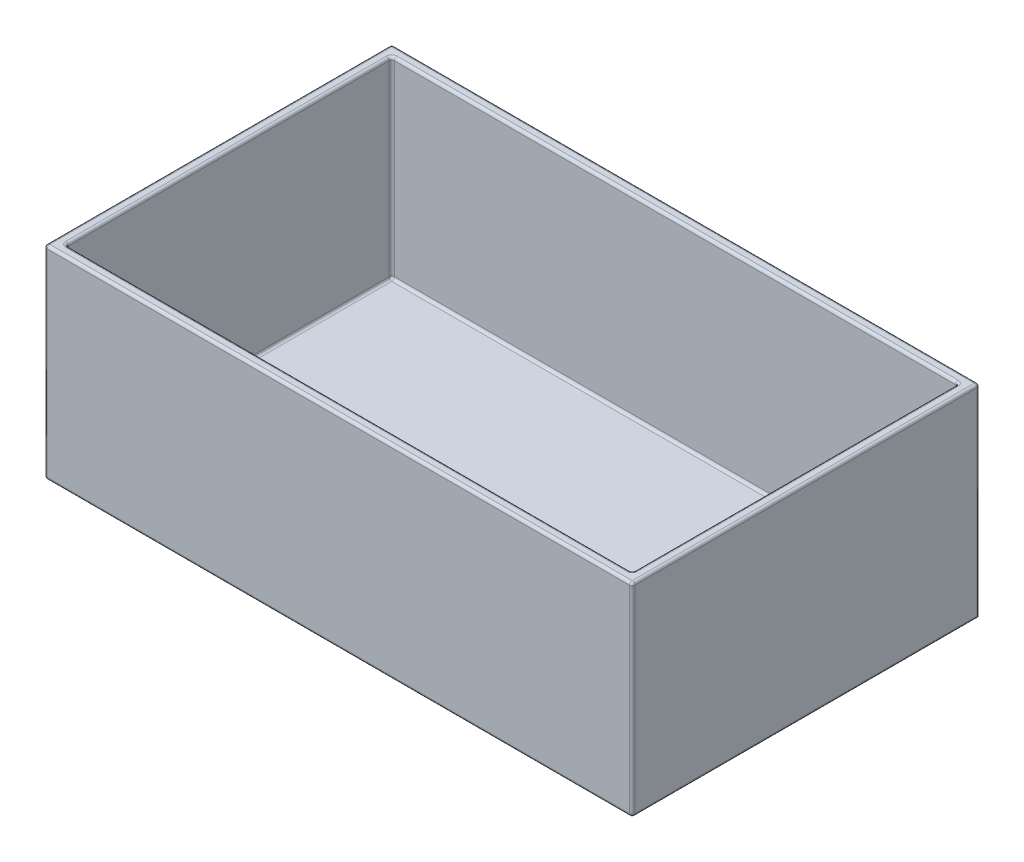
from build123d import *

# Parameters (mm, degrees)
SKETCH1_W           = 110
SKETCH1_H           = 65
BOSS_EXTRUDE1_DEPTH = 38
SKETCH2_W           = 106
SKETCH2_H           = 61
CUT_EXTRUDE1_DEPTH  = 36
SKETCH3_W           = 2
SKETCH3_H           = 61
BOSS_EXTRUDE2_DEPTH = 5
FILLET4_R           = 0.5


with BuildPart() as part:
    # Sketch1 → Boss-Extrude1 (new body)
    with BuildSketch(Plane(origin=(0, 0, 0), x_dir=(1, 0, 0), z_dir=(0, 1, 0))):
        with Locations((11.911764706, 4.558823529)):
            Rectangle(SKETCH1_W, SKETCH1_H)
    extrude(amount=BOSS_EXTRUDE1_DEPTH)

    # Sketch2 → Cut-Extrude1 (cut)
    with BuildSketch(Plane(origin=(0, 38, 0), x_dir=(1, 0, 0), z_dir=(0, 1, 0))):
        with Locations((11.911764706, 4.558823529)):
            Rectangle(SKETCH2_W, SKETCH2_H)
    extrude(amount=-CUT_EXTRUDE1_DEPTH, mode=Mode.SUBTRACT)

    # Sketch3 → Boss-Extrude2 (add)
    with BuildSketch(Plane(origin=(0, 2, 0), x_dir=(1, 0, 0), z_dir=(0, 1, 0))):
        with Locations((37.911764706, 4.558823529)):
            Rectangle(SKETCH3_W, SKETCH3_H)
    extrude(amount=BOSS_EXTRUDE2_DEPTH)

    # Fillet4
    fillet4_edges = [part.edges().sort_by_distance(p)[0] for p in [
        (66.911764706, 38, -4.558823529),
        (11.911764706, 38, -37.058823529),
        (-41.088235294, 2, -4.558823529),
        (-41.088235294, 20, 25.941176471),
        (51.911764706, 2, -35.058823529),
        (-41.088235294, 20, -35.058823529),
        (64.911764706, 2, -4.558823529),
        (64.911764706, 20, -35.058823529),
        (-2.088235294, 2, 25.941176471),
        (64.911764706, 20, 25.941176471),
        (-41.088235294, 38, -4.558823529),
        (11.911764706, 38, 25.941176471),
        (64.911764706, 38, -4.558823529),
        (11.911764706, 38, -35.058823529),
        (51.911764706, 2, 25.941176471),
        (-2.088235294, 2, -35.058823529),
        (37.911764706, 7, -35.058823529),
        (38.911764706, 4.5, -35.058823529),
        (36.911764706, 2, -4.558823529),
        (36.911764706, 4.5, -35.058823529),
        (36.911764706, 4.5, 25.941176471),
        (38.911764706, 7, -4.558823529),
        (38.911764706, 4.5, 25.941176471),
        (36.911764706, 7, -4.558823529),
        (37.911764706, 7, 25.941176471),
        (38.911764706, 2, -4.558823529),
        (-43.088235294, 38, -4.558823529),
        (66.911764706, 0, -4.558823529),
        (11.911764706, 0, 27.941176471),
        (-43.088235294, 0, -4.558823529),
        (11.911764706, 38, 27.941176471),
        (-43.088235294, 19, -37.058823529),
        (66.911764706, 19, -37.058823529),
        (66.911764706, 19, 27.941176471),
        (-43.088235294, 19, 27.941176471),
    ]]
    fillet(fillet4_edges, radius=FILLET4_R)


solid = part.part
